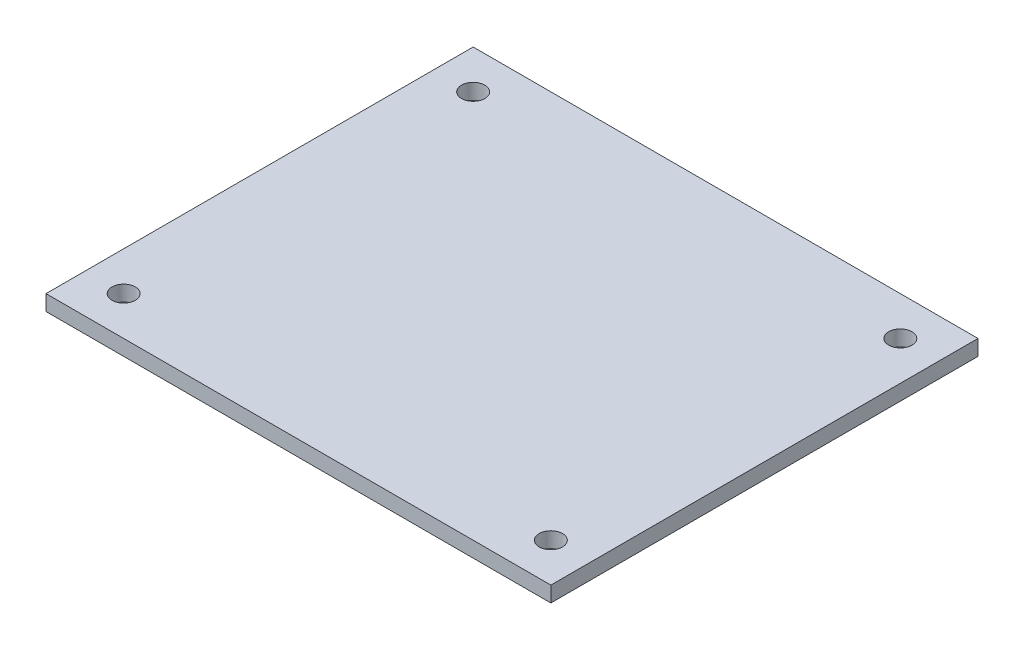
from build123d import *

# Parameters (mm, degrees)
CROQUIS2_W              = 65
CROQUIS2_H              = 55
SALIENTE_EXTRUIR1_DEPTH = 2
CROQUIS3_R              = 1.5
CORTAR_EXTRUIR1_DEPTH   = 3


with BuildPart() as part:
    # Croquis2 → Saliente-Extruir1 (new body)
    with BuildSketch(Plane(origin=(0, 0, 0), x_dir=(1, 0, 0), z_dir=(0, 1, 0))):
        Rectangle(CROQUIS2_W, CROQUIS2_H)
    extrude(amount=SALIENTE_EXTRUIR1_DEPTH)

    # Croquis3 → Cortar-Extruir1 (cut, through all)
    with BuildSketch(Plane(origin=(0, 2, 0), x_dir=(1, 0, 0), z_dir=(0, 1, 0))):
        with Locations((-27.5, 22.5)):
            Circle(CROQUIS3_R)
        with Locations((27.5, 22.5)):
            Circle(CROQUIS3_R)
        with Locations((27.5, -22.5)):
            Circle(CROQUIS3_R)
        with Locations((-27.5, -22.5)):
            Circle(CROQUIS3_R)
    extrude(amount=-CORTAR_EXTRUIR1_DEPTH, mode=Mode.SUBTRACT)


solid = part.part
